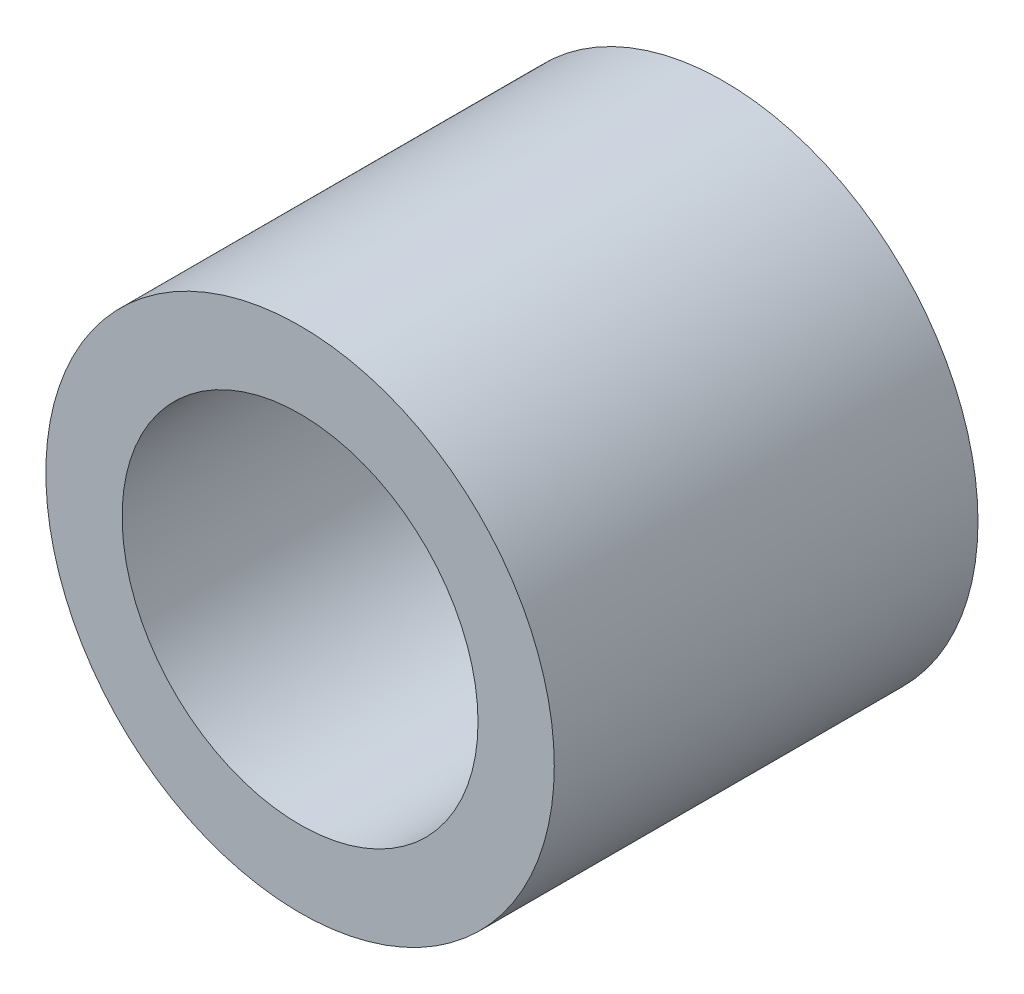
from build123d import *

# Parameters (mm, degrees)
SKETCH_1_R      = 3
SKETCH_1_R_2    = 2.1
EXTRUDE_1_DEPTH = 5


with BuildPart() as part:
    # ｽｹｯﾁ1 → ﾎﾞｽ - 押し出し1 (new body)
    with BuildSketch(Plane.XY):
        Circle(SKETCH_1_R)
        Circle(SKETCH_1_R_2, mode=Mode.SUBTRACT)
    extrude(amount=EXTRUDE_1_DEPTH)


solid = part.part
